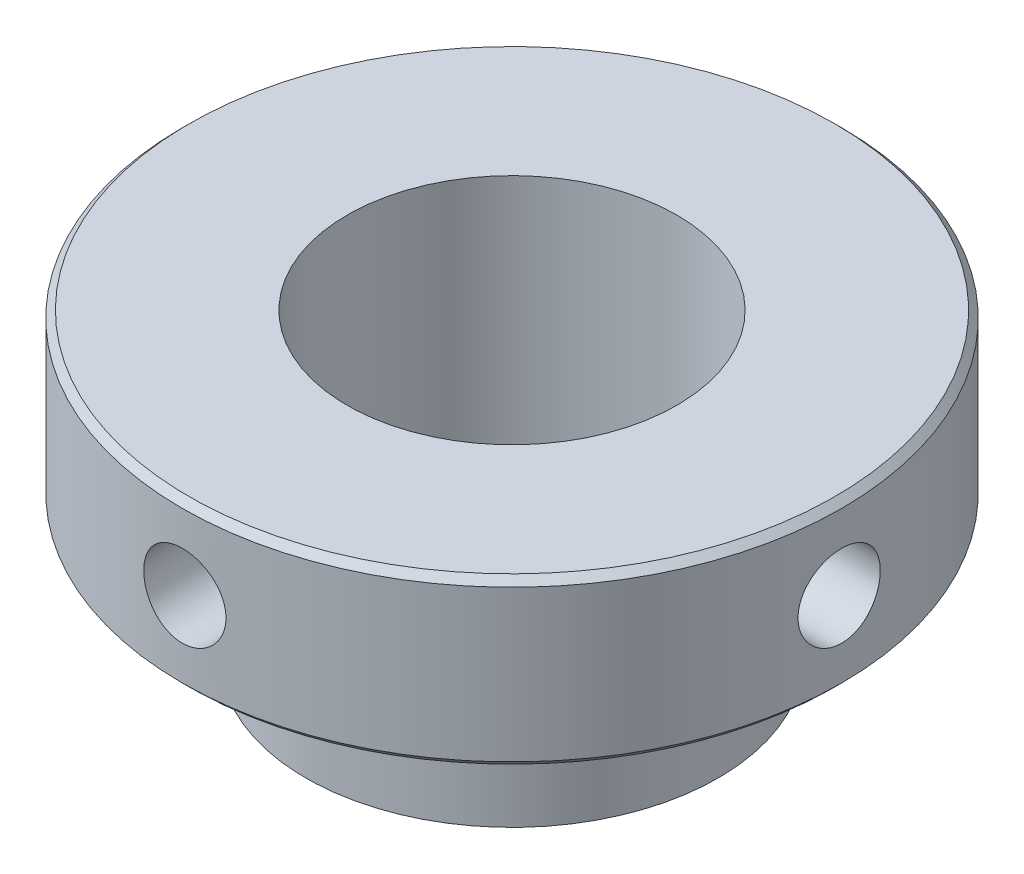
from build123d import *

# Parameters (mm, degrees)
CIRPATTERN1_COUNT = 4


with BuildPart() as part:
    # Sketch1 → Revolve2 (revolve)
    with BuildSketch(Plane.XY):
        Polygon((1.5, 0), (1.5, 2.75), (2.938, 2.75), (3, 2.688), (3, 1.312), (2.938, 1.25), (1.875, 1.25), (1.875, 0), align=None)
    revolve(axis=Axis((0, 0, 0), (0, 1, 0)))

    # Sketch4 → Cut-Revolve1 (revolve, cut)
    with BuildSketch(Plane.XY):
        Polygon((-3.475, 2.374), (-2.175, 2.374), (-1.875, 2), (-3.475, 2), align=None)
    cut_revolve1 = revolve(axis=Axis((-3.475, 2, 0), (1, 0, 0)), mode=Mode.SUBTRACT)

    # CirPattern1: Cut-Revolve1 ×4 about axis
    cirpattern1_axis = Axis((0, 2.75, 0), (0, -1, 0))
    for i in range(1, CIRPATTERN1_COUNT):
        add(cut_revolve1.rotate(cirpattern1_axis, i * 360 / CIRPATTERN1_COUNT), mode=Mode.SUBTRACT)


solid = part.part
